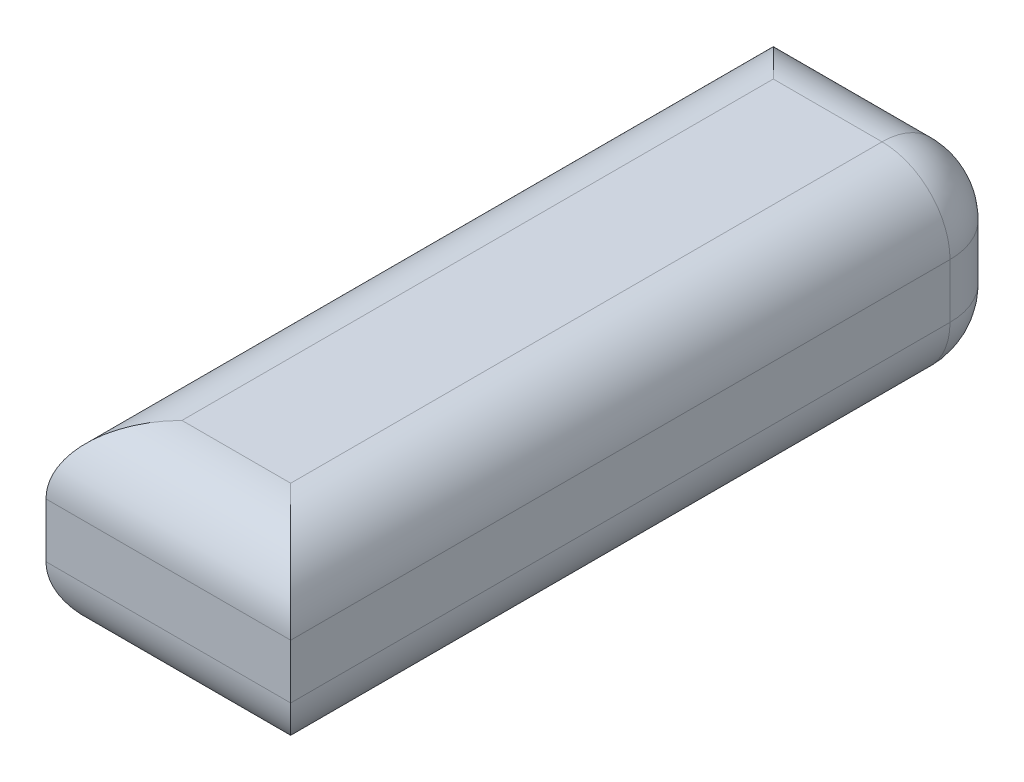
from build123d import *

# Parameters (mm, degrees)
SKETCH1_W           = 36
SKETCH1_H           = 107
BOSS_EXTRUDE1_DEPTH = 28
FILLET1_R           = 10


with BuildPart() as part:
    # Sketch1 → Boss-Extrude1 (new body)
    with BuildSketch(Plane(origin=(0, 0, 0), x_dir=(1, 0, 0), z_dir=(0, 1, 0))):
        with Locations((18, 53.5)):
            Rectangle(SKETCH1_W, SKETCH1_H)
    extrude(amount=BOSS_EXTRUDE1_DEPTH)

    # Fillet1
    fillet1_edges = [part.edges().sort_by_distance(p)[0] for p in [
        (36, 28, -53.5),
        (18, 28, -107),
        (0, 28, -53.5),
        (18, 0, -107),
        (36, 0, -53.5),
        (18, 0, 0),
        (0, 0, -53.5),
        (18, 28, 0),
        (36, 14, -107),
    ]]
    fillet(fillet1_edges, radius=FILLET1_R)


solid = part.part
